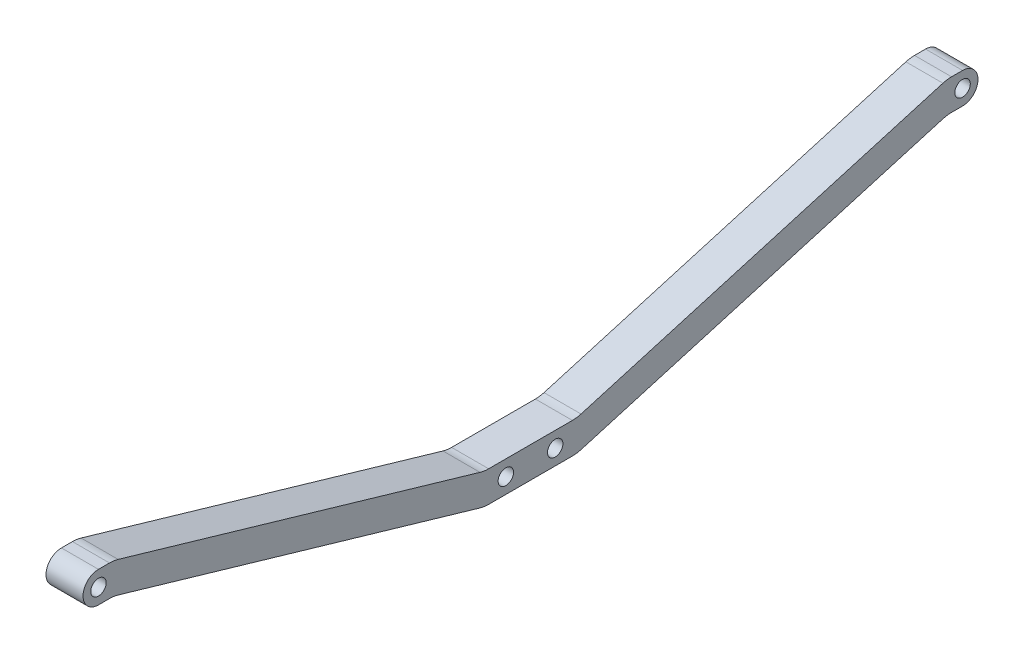
from build123d import *

# Parameters (mm, degrees)
CROQUIS1_R              = 2.5
SALIENTE_EXTRUIR1_DEPTH = 12
REDONDEO1_R             = 10


with BuildPart() as part:
    # Croquis1 → Saliente-Extruir1 (new body)
    with BuildSketch(Plane(origin=(0, 0, 0), x_dir=(0, 0, -1), z_dir=(1, 0, 0))):
        with BuildLine():
            Line((-15, -30), (15, -30))
            Line((15, -30), (135, 5))
            Line((135, 5), (140, 5))
            ThreePointArc((140, 5), (145, 0), (140, -5))
            Line((140, -5), (135, -5))
            Line((135, -5), (15, -40))
            Line((15, -40), (-15, -40))
            Line((-15, -40), (-135, -5))
            Line((-135, -5), (-140, -5))
            ThreePointArc((-140, -5), (-145, 0), (-140, 5))
            Line((-140, 5), (-135, 5))
            Line((-135, 5), (-15, -30))
        make_face()
        with Locations((-8, -35)):
            Circle(CROQUIS1_R, mode=Mode.SUBTRACT)
        with Locations((8, -35)):
            Circle(CROQUIS1_R, mode=Mode.SUBTRACT)
        with Locations((-140, 0)):
            Circle(CROQUIS1_R, mode=Mode.SUBTRACT)
        with Locations((140, 0)):
            Circle(CROQUIS1_R, mode=Mode.SUBTRACT)
    extrude(amount=SALIENTE_EXTRUIR1_DEPTH)

    # Redondeo1
    redondeo1_edges = [part.edges().sort_by_distance(p)[0] for p in [
        (6, -5, -135),
        (6, -40, -15),
        (6, -40, 15),
        (6, -5, 135),
        (6, 5, 135),
        (6, -30, 15),
        (6, -30, -15),
        (6, 5, -135),
    ]]
    fillet(redondeo1_edges, radius=REDONDEO1_R)


solid = part.part
